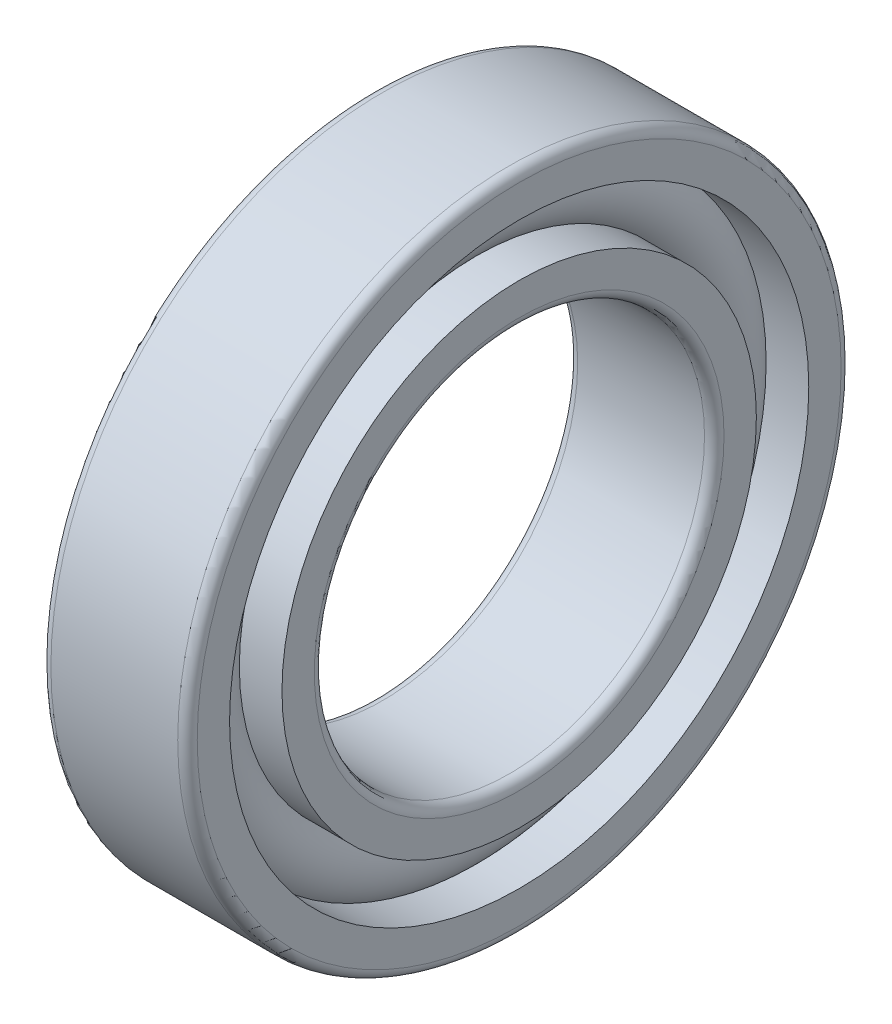
from build123d import *

# Parameters (mm, degrees)
ZAOBLIT1_R = 1
ZAOBLIT2_R = 1
SKICA3_R   = 4.123903424
SKICA3_R_2 = 4.113903424


with BuildPart() as part:
    # Skica2 → Otočit kolem osy1 (revolve)
    with BuildSketch(Plane.XY):
        with BuildLine():
            Line((-7.5, 34), (7.5, 34))
            Line((7.5, 34), (7.5, 29.685855137))
            Line((7.5, 29.685855137), (3.12933885, 29.685855137))
            ThreePointArc((3.12933885, 29.685855137), (0, 31.123903424), (-3.12933885, 29.685855137))
            Line((-3.12933885, 29.685855137), (-7.5, 29.685855137))
            Line((-7.5, 29.685855137), (-7.5, 34))
        make_face()
        with BuildLine():
            Line((7.5, 20), (-7.5, 20))
            Line((-7.5, 20), (-7.5, 24.314144863))
            Line((-7.5, 24.314144863), (-3.12933885, 24.314144863))
            ThreePointArc((-3.12933885, 24.314144863), (0, 22.876096576), (3.12933885, 24.314144863))
            Line((3.12933885, 24.314144863), (7.5, 24.314144863))
            Line((7.5, 24.314144863), (7.5, 20))
        make_face()
    revolve(axis=Axis((0, 0, 0), (-1, 0, 0)))

    # Zaoblit1
    zaoblit1_edges = [part.edges().sort_by_distance(p)[0] for p in [
        (7.5, -34, 0),
        (-7.5, -34, 0),
    ]]
    fillet(zaoblit1_edges, radius=ZAOBLIT1_R)

    # Zaoblit2
    zaoblit2_edges = [part.edges().sort_by_distance(p)[0] for p in [
        (7.5, -20, 0),
        (-7.5, -20, 0),
    ]]
    fillet(zaoblit2_edges, radius=ZAOBLIT2_R)


with BuildPart() as body_2:
    # Skica3 → Otočit kolem osy2 (revolve)
    with BuildSketch(Plane.XY):
        with Locations((0, 27)):
            Circle(SKICA3_R)
        with Locations((0, 27)):
            Circle(SKICA3_R_2, mode=Mode.SUBTRACT)
    revolve(axis=Axis((0, 0, 0), (1, 0, 0)))


solid = Compound([part.part, body_2.part])
